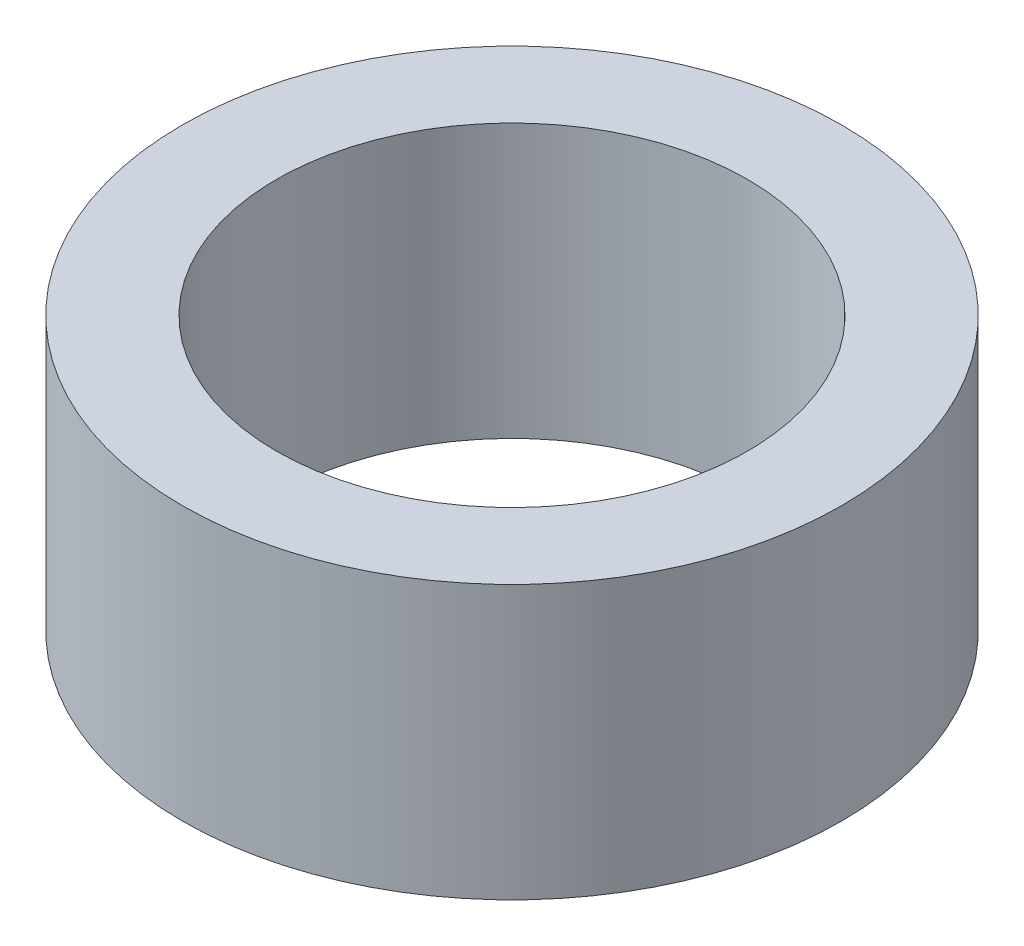
from build123d import *

# Parameters (mm, degrees)
SCHIZZO1_R                   = 10.5
SCHIZZO1_R_2                 = 7.5
ESTRUSIONE_ESTRUSIONE1_DEPTH = 8.7


with BuildPart() as part:
    # Schizzo1 → Estrusione-Estrusione1 (new body)
    with BuildSketch(Plane(origin=(0, 0, 0), x_dir=(1, 0, 0), z_dir=(0, 1, 0))):
        Circle(SCHIZZO1_R)
        Circle(SCHIZZO1_R_2, mode=Mode.SUBTRACT)
    extrude(amount=ESTRUSIONE_ESTRUSIONE1_DEPTH)


solid = part.part
